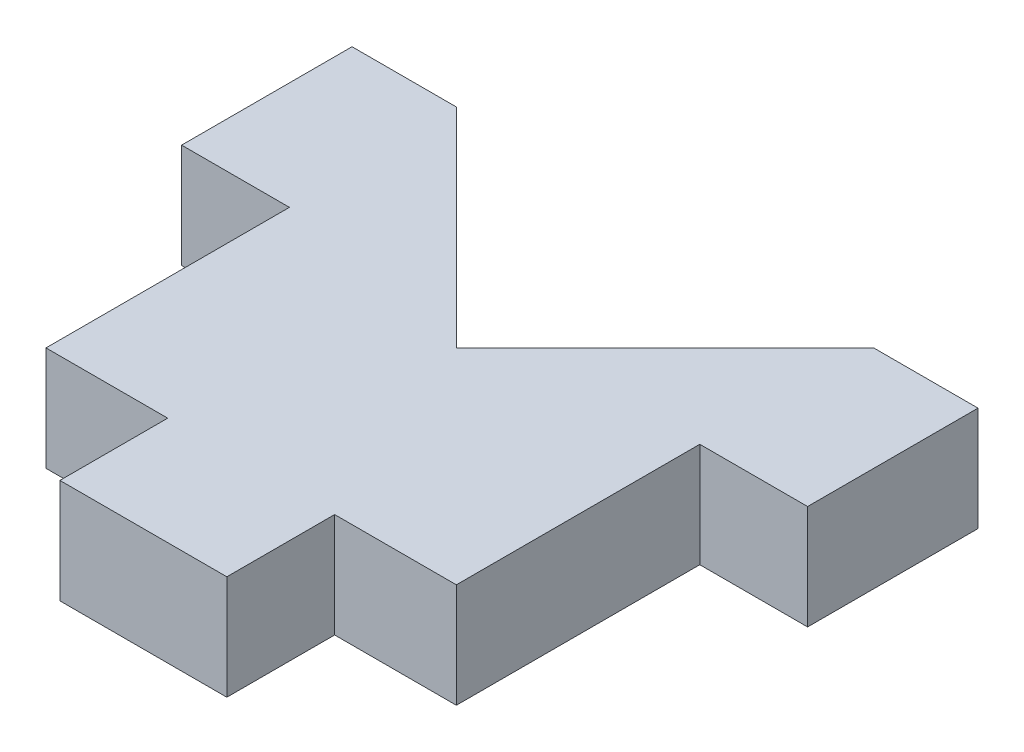
from build123d import *

# Parameters (mm, degrees)
BOSS_EXTRUDE1_DEPTH = 3
CUT_EXTRUDE3_DEPTH  = 4


with BuildPart() as part:
    # Sketch1 → Boss-Extrude1 (new body)
    with BuildSketch(Plane(origin=(0, 0, 0), x_dir=(1, 0, 0), z_dir=(0, 1, 0))):
        Polygon((-6, 15), (-9, 15), (-9, 0), (9, 0), (9, 15), (6, 15), (0, 9), align=None)
    extrude(amount=BOSS_EXTRUDE1_DEPTH)

    # Sketch6 → Cut-Extrude3 (cut, through all)
    with BuildSketch(Plane(origin=(0, 0, 0), x_dir=(1, 0, 0), z_dir=(0, 1, 0))):
        Polygon((-5.9, 3.1), (-5.9, 10.1), (-9.1, 10.1), (-9.1, -0.1), (-2.4, -0.1), (-2.4, 3.1), align=None)
        Polygon((9.1, 10.1), (5.9, 10.1), (5.9, 3.1), (2.4, 3.1), (2.4, -0.1), (9.1, -0.1), align=None)
    extrude(amount=CUT_EXTRUDE3_DEPTH, mode=Mode.SUBTRACT)


solid = part.part
